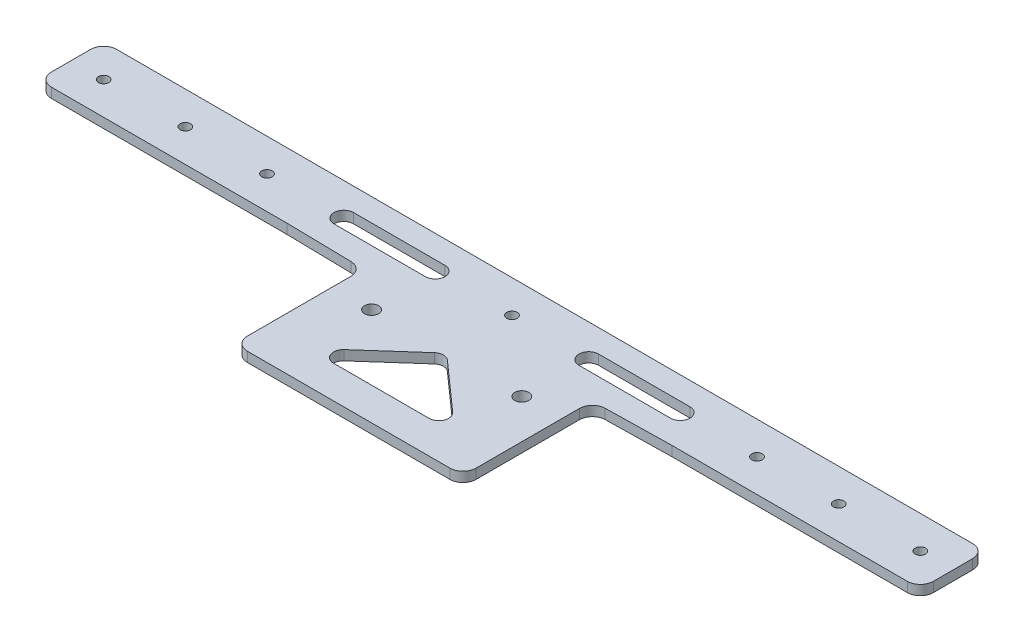
from build123d import *

# Parameters (mm, degrees)
SKETCH_1_W          = 270
SKETCH_1_H          = 60
EXTRUDE_1_DEPTH     = 3
SKETCH_2_R          = 2.15
SKETCH_2_R_2        = 1.6
CUT_EXTRUDE_1_DEPTH = 3
SKETCH_3_R          = 1.6
CUT_EXTRUDE_2_DEPTH = 10
CUT_EXTRUDE_3_DEPTH = 10
FILLET_1_R          = 3
FILLET_2_R          = 4
SKETCH_5_W          = 100
SKETCH_5_H          = 40
CUT_EXTRUDE_4_DEPTH = 10
EXTRUDE_2_DEPTH     = 3
EXTRUDE_9_DEPTH     = 3
EXTRUDE_10_DEPTH    = 3
EXTRUDE_11_DEPTH    = 3
EXTRUDE_13_DEPTH    = 3
EXTRUDE_14_DEPTH    = 3
EXTRUDE_16_DEPTH    = 3
EXTRUDE_17_DEPTH    = 3
EXTRUDE_18_DEPTH    = 3
EXTRUDE_19_DEPTH    = 3
CUT_EXTRUDE_5_DEPTH = 4
FILLET_4_R          = 4


with BuildPart() as part:
    # 草图1 → 凸台-拉伸1 (new body)
    with BuildSketch(Plane(origin=(0, 0, 0), x_dir=(1, 0, 0), z_dir=(0, 1, 0))):
        Rectangle(SKETCH_1_W, SKETCH_1_H)
    extrude(amount=EXTRUDE_1_DEPTH)

    # 草图2 → 切除-拉伸1 (cut)
    with BuildSketch(Plane(origin=(0, 3, 0), x_dir=(1, 0, 0), z_dir=(0, 1, 0))):
        with Locations((-23, 0)):
            Circle(SKETCH_2_R)
        with Locations((23, 0)):
            Circle(SKETCH_2_R)
        with Locations((-125, -20)):
            Circle(SKETCH_2_R_2)
        with Locations((-125, -60)):
            Circle(SKETCH_2_R_2)
        with Locations((125, -60)):
            Circle(SKETCH_2_R_2)
        with Locations((125, -20)):
            Circle(SKETCH_2_R_2)
    extrude(amount=-CUT_EXTRUDE_1_DEPTH, mode=Mode.SUBTRACT)

    # 草图3 → 切除-拉伸2 (cut)
    with BuildSketch(Plane(origin=(0, 3, 0), x_dir=(1, 0, 0), z_dir=(0, 1, 0))):
        with Locations((125, 20)):
            Circle(SKETCH_3_R)
        with Locations((100, 20)):
            Circle(SKETCH_3_R)
        with Locations((75, 20)):
            Circle(SKETCH_3_R)
        with Locations((0, 20)):
            Circle(SKETCH_3_R)
        with Locations((-75, 20)):
            Circle(SKETCH_3_R)
        with Locations((-100, 20)):
            Circle(SKETCH_3_R)
        with Locations((-125, 20)):
            Circle(SKETCH_3_R)
    extrude(amount=-CUT_EXTRUDE_2_DEPTH, mode=Mode.SUBTRACT)

    # 草图4 → 切除-拉伸3 (cut)
    with BuildSketch(Plane(origin=(0, 3, 0), x_dir=(1, 0, 0), z_dir=(0, 1, 0))):
        with BuildLine():
            Line((-112.832473586, 10.419213325), (-112.99590583, 10.347711719))
            ThreePointArc((-112.99590583, 10.347711719), (-119.580786675, 12.924404223), (-117.00409417, 19.509285068))
            Line((-117.00409417, 19.509285068), (-116.840661926, 19.580786675))
            ThreePointArc((-116.840661926, 19.580786675), (-110.255781081, 17.00409417), (-112.832473586, 10.419213325))
        make_face()
        with BuildLine():
            Line((-79.771332565, 7.419213325), (-112.99590583, -7.116537478))
            ThreePointArc((-112.99590583, -7.116537478), (-119.580786675, -4.539844974), (-117.00409417, 2.045035871))
            Line((-117.00409417, 2.045035871), (-83.779520905, 16.580786675))
            ThreePointArc((-83.779520905, 16.580786675), (-77.194640061, 14.00409417), (-79.771332565, 7.419213325))
        make_face()
        with BuildLine():
            Line((-32.99590583, 10.419213325), (-112.99590583, -24.580786675))
            ThreePointArc((-112.99590583, -24.580786675), (-119.580786675, -22.00409417), (-117.00409417, -15.419213325))
            Line((-117.00409417, -15.419213325), (-37.00409417, 19.580786675))
            ThreePointArc((-37.00409417, 19.580786675), (-30.419213325, 17.00409417), (-32.99590583, 10.419213325))
        make_face()
        with BuildLine():
            Line((-32.99590583, -10.045035871), (-66.220479095, -24.580786675))
            ThreePointArc((-66.220479095, -24.580786675), (-72.805359939, -22.00409417), (-70.228667435, -15.419213325))
            Line((-70.228667435, -15.419213325), (-37.00409417, -0.883462522))
            ThreePointArc((-37.00409417, -0.883462522), (-30.419213325, -3.460155026), (-32.99590583, -10.045035871))
        make_face()
        with BuildLine():
            Line((-32.99590583, -24.509285068), (-33.159338074, -24.580786675))
            ThreePointArc((-33.159338074, -24.580786675), (-39.744218919, -22.00409417), (-37.167526414, -15.419213325))
            Line((-37.167526414, -15.419213325), (-37.00409417, -15.347711719))
            ThreePointArc((-37.00409417, -15.347711719), (-30.419213325, -17.924404223), (-32.99590583, -24.509285068))
        make_face()
        with BuildLine():
            Line((32.99590583, -24.509285068), (33.159338074, -24.580786675))
            ThreePointArc((33.159338074, -24.580786675), (39.744218919, -22.00409417), (37.167526414, -15.419213325))
            Line((37.167526414, -15.419213325), (37.00409417, -15.347711719))
            ThreePointArc((37.00409417, -15.347711719), (30.419213325, -17.924404223), (32.99590583, -24.509285068))
        make_face()
        with BuildLine():
            Line((32.99590583, -10.045035871), (66.220479095, -24.580786675))
            ThreePointArc((66.220479095, -24.580786675), (72.805359939, -22.00409417), (70.228667435, -15.419213325))
            Line((70.228667435, -15.419213325), (37.00409417, -0.883462522))
            ThreePointArc((37.00409417, -0.883462522), (30.419213325, -3.460155026), (32.99590583, -10.045035871))
        make_face()
        with BuildLine():
            Line((32.99590583, 10.419213325), (112.99590583, -24.580786675))
            ThreePointArc((112.99590583, -24.580786675), (119.580786675, -22.00409417), (117.00409417, -15.419213325))
            Line((117.00409417, -15.419213325), (37.00409417, 19.580786675))
            ThreePointArc((37.00409417, 19.580786675), (30.419213325, 17.00409417), (32.99590583, 10.419213325))
        make_face()
        with BuildLine():
            Line((79.771332565, 7.419213325), (112.99590583, -7.116537478))
            ThreePointArc((112.99590583, -7.116537478), (119.580786675, -4.539844974), (117.00409417, 2.045035871))
            Line((117.00409417, 2.045035871), (83.779520905, 16.580786675))
            ThreePointArc((83.779520905, 16.580786675), (77.194640061, 14.00409417), (79.771332565, 7.419213325))
        make_face()
        with BuildLine():
            Line((112.832473586, 10.419213325), (112.99590583, 10.347711719))
            ThreePointArc((112.99590583, 10.347711719), (119.580786675, 12.924404223), (117.00409417, 19.509285068))
            Line((117.00409417, 19.509285068), (116.840661926, 19.580786675))
            ThreePointArc((116.840661926, 19.580786675), (110.255781081, 17.00409417), (112.832473586, 10.419213325))
        make_face()
        Polygon((0, -20), (-22.5, -20), (0, 0), (22.5, -20), align=None)
    extrude(amount=-CUT_EXTRUDE_3_DEPTH, mode=Mode.SUBTRACT)

    # 圆角1
    fillet_1_edges = [part.edges().sort_by_distance(p)[0] for p in [
        (22.5, 1.5, 20),
        (-22.5, 1.5, 20),
        (0, 1.5, 0),
    ]]
    fillet(fillet_1_edges, radius=FILLET_1_R)

    # 圆角2
    fillet_2_edges = [part.edges().sort_by_distance(p)[0] for p in [
        (135, 1.5, 30),
        (-135, 1.5, 30),
        (-135, 1.5, -30),
        (135, 1.5, -30),
    ]]
    fillet(fillet_2_edges, radius=FILLET_2_R)

    # 草图5 → 切除-拉伸4 (cut)
    with BuildSketch(Plane(origin=(0, 3, 0), x_dir=(1, 0, 0), z_dir=(0, 1, 0))):
        with Locations((-85, -10)):
            Rectangle(SKETCH_5_W, SKETCH_5_H)
        with Locations((85, -10)):
            Rectangle(SKETCH_5_W, SKETCH_5_H)
    extrude(amount=-CUT_EXTRUDE_4_DEPTH, mode=Mode.SUBTRACT)

    # 草图6 → 凸台-拉伸2 (add)
    with BuildSketch(Plane(origin=(0, 3, 0), x_dir=(1, 0, 0), z_dir=(0, 1, 0))):
        with BuildLine():
            Line((-111.519942965, 10), (-118.153192546, 10))
            ThreePointArc((-118.153192546, 10), (-114.836567756, 21), (-111.519942965, 10))
        make_face()
    extrude(amount=-EXTRUDE_2_DEPTH)

    # 草图7 → 凸台-拉伸9 (add)
    with BuildSketch(Plane(origin=(0, 3, 0), x_dir=(1, 0, 0), z_dir=(0, 1, 0))):
        with BuildLine():
            Line((-98.821319018, 10), (-83.779520905, 16.580786675))
            ThreePointArc((-83.779520905, 16.580786675), (-78.241472851, 15.537113222), (-77.19285104, 10))
            Line((-77.19285104, 10), (-98.821319018, 10))
        make_face()
    extrude(amount=-EXTRUDE_9_DEPTH)

    # 草图8 → 凸台-拉伸10 (add)
    with BuildSketch(Plane(origin=(0, 3, 0), x_dir=(1, 0, 0), z_dir=(0, 1, 0))):
        with BuildLine():
            Line((-58.90303514, 10), (-35, 9.542422126))
            Line((-35, 9.542422126), (-32.99590583, 10.419213325))
            ThreePointArc((-32.99590583, 10.419213325), (-30.419213325, 17.00409417), (-37.00409417, 19.580786675))
            Line((-37.00409417, 19.580786675), (-58.90303514, 10))
        make_face()
    extrude(amount=-EXTRUDE_10_DEPTH)

    # 草图9 → 凸台-拉伸11 (add)
    with BuildSketch(Plane(origin=(0, 3, 0), x_dir=(1, 0, 0), z_dir=(0, 1, 0))):
        with BuildLine():
            Line((-35, -0.464249197), (-35, -10.921827071))
            Line((-35, -10.921827071), (-32.99590583, -10.045035871))
            ThreePointArc((-32.99590583, -10.045035871), (-30.105925349, -4.440514214), (-35, -0.464249197))
        make_face()
    extrude(amount=-EXTRUDE_11_DEPTH)

    # 草图10 → 凸台-拉伸13 (add)
    with BuildSketch(Plane(origin=(0, 3, 0), x_dir=(1, 0, 0), z_dir=(0, 1, 0))):
        with BuildLine():
            Line((-35, -14.928498393), (-35, -24.997328276))
            ThreePointArc((-35, -24.997328276), (-29.965585058, -19.962913335), (-35, -14.928498393))
        make_face()
    extrude(amount=-EXTRUDE_13_DEPTH)

    # 草图11 → 凸台-拉伸14 (add)
    with BuildSketch(Plane(origin=(0, 3, 0), x_dir=(1, 0, 0), z_dir=(0, 1, 0))):
        with BuildLine():
            Line((35, -0.464249197), (35, -10.921827071))
            ThreePointArc((35, -10.921827071), (29.771211063, -5.693038134), (35, -0.464249197))
        make_face()
    extrude(amount=-EXTRUDE_14_DEPTH)

    # 草图12 → 凸台-拉伸16 (add)
    with BuildSketch(Plane(origin=(0, 3, 0), x_dir=(1, 0, 0), z_dir=(0, 1, 0))):
        with BuildLine():
            Line((35, -14.928498393), (35, -24.997328276))
            ThreePointArc((35, -24.997328276), (29.965585058, -19.962913335), (35, -14.928498393))
        make_face()
    extrude(amount=-EXTRUDE_16_DEPTH)

    # 草图13 → 凸台-拉伸17 (add)
    with BuildSketch(Plane(origin=(0, 3, 0), x_dir=(1, 0, 0), z_dir=(0, 1, 0))):
        with BuildLine():
            Line((58.90303514, 10), (37.00409417, 19.580786675))
            ThreePointArc((37.00409417, 19.580786675), (30.419213325, 17.00409417), (32.99590583, 10.419213325))
            Line((32.99590583, 10.419213325), (35, 9.542422126))
            Line((35, 9.542422126), (58.90303514, 10))
        make_face()
    extrude(amount=-EXTRUDE_17_DEPTH)

    # 草图14 → 凸台-拉伸18 (add)
    with BuildSketch(Plane(origin=(0, 3, 0), x_dir=(1, 0, 0), z_dir=(0, 1, 0))):
        with BuildLine():
            Line((98.821319018, 10), (83.779520905, 16.580786675))
            ThreePointArc((83.779520905, 16.580786675), (78.241472851, 15.537113222), (77.19285104, 10))
            Line((77.19285104, 10), (98.821319018, 10))
        make_face()
    extrude(amount=-EXTRUDE_18_DEPTH)

    # 草图15 → 凸台-拉伸19 (add)
    with BuildSketch(Plane(origin=(0, 3, 0), x_dir=(1, 0, 0), z_dir=(0, 1, 0))):
        with BuildLine():
            Line((116.732439942, 10), (112.940695569, 10))
            ThreePointArc((112.940695569, 10), (114.836567756, 20.347366768), (116.732439942, 10))
        make_face()
    extrude(amount=-EXTRUDE_19_DEPTH)

    # 草图16 → 切除-拉伸5 (cut, through all)
    with BuildSketch(Plane(origin=(0, 3, 0), x_dir=(1, 0, 0), z_dir=(0, 1, 0))):
        with BuildLine():
            Line((-23.5, 17), (-51.5, 17))
            ThreePointArc((-51.5, 17), (-54.5, 20), (-51.5, 23))
            Line((-51.5, 23), (-23.5, 23))
            ThreePointArc((-23.5, 23), (-20.5, 20), (-23.5, 17))
        make_face()
        with BuildLine():
            Line((23.5, 17), (51.5, 17))
            ThreePointArc((51.5, 17), (54.5, 20), (51.5, 23))
            Line((51.5, 23), (23.5, 23))
            ThreePointArc((23.5, 23), (20.5, 20), (23.5, 17))
        make_face()
    extrude(amount=-CUT_EXTRUDE_5_DEPTH, mode=Mode.SUBTRACT)

    # 圆角4
    fillet_4_edges = [part.edges().sort_by_distance(p)[0] for p in [
        (35, 1.5, -9.542422126),
        (-135, 1.5, -10),
        (-35, 1.5, -9.542422126),
        (-35, 1.5, 30),
        (35, 1.5, 30),
        (135, 1.5, -10),
    ]]
    fillet(fillet_4_edges, radius=FILLET_4_R)


solid = part.part
